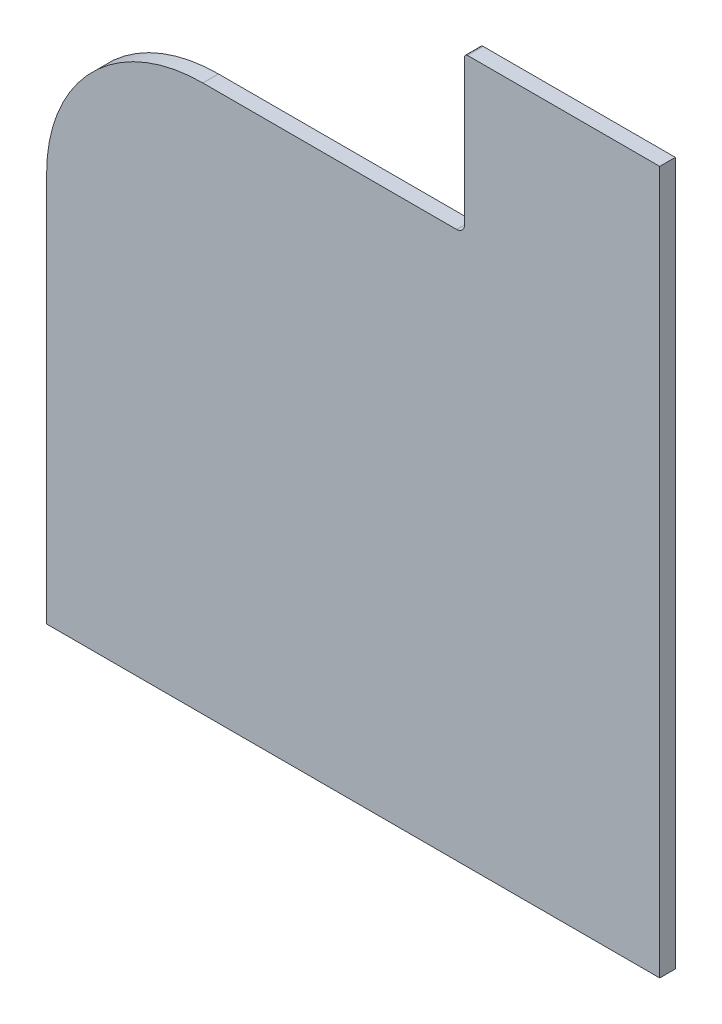
from build123d import *

# Parameters (mm, degrees)
BOSS_EXTRUDE1_DEPTH = 20
FILLET1_R           = 4


with BuildPart() as part:
    # Sketch1 → Boss-Extrude1 (new body)
    with BuildSketch(Plane.XY):
        with BuildLine():
            Line((-300, 400), (25, 400))
            ThreePointArc((25, 400), (32.071067812, 402.928932188), (35, 410))
            Line((35, 410), (35, 600))
            Line((35, 600), (285, 600))
            Line((285, 600), (285, 100))
            Line((285, 100), (285, -300))
            Line((285, -300), (-500, -300))
            Line((-500, -300), (-500, 200))
            ThreePointArc((-500, 200), (-441.421356237, 341.421356237), (-300, 400))
        make_face()
    extrude(amount=BOSS_EXTRUDE1_DEPTH)

    # Fillet1
    fillet1_edges = [part.edges().sort_by_distance(p)[0] for p in [
        (35, 600, 10),
    ]]
    fillet(fillet1_edges, radius=FILLET1_R)


solid = part.part
